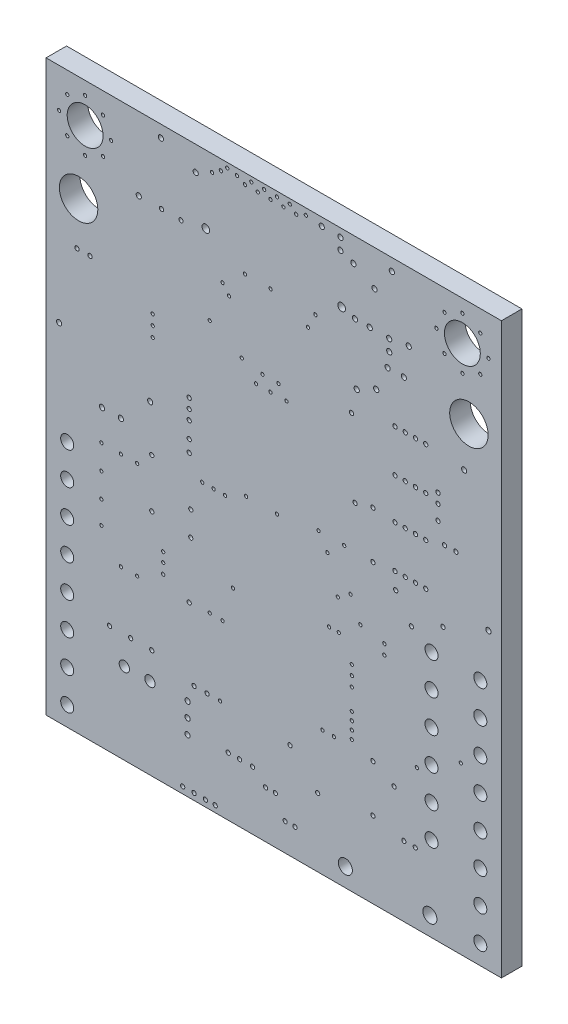
from build123d import *

# Parameters (mm, degrees)
SKETCH1_W           = 35.56
SKETCH1_H           = 44.45
BOARD_OUTLINE_DEPTH = 1.6
SKETCH2_R           = 0.3
SKETCH2_R_2         = 0.127
SKETCH2_R_3         = 0.1651
SKETCH2_R_4         = 0.2032
NPTH_DEPTH          = 2.6
SKETCH3_R           = 1.4
SKETCH3_R_2         = 0.51
SKETCH3_R_3         = 1.5
SKETCH3_R_4         = 0.55
SKETCH3_R_5         = 0.4
PTH_DEPTH           = 2.6


with BuildPart() as part:
    # Sketch1 → Board_Outline (new body)
    with BuildSketch(Plane.XY):
        with Locations((17.78, 22.225)):
            Rectangle(SKETCH1_W, SKETCH1_H)
    extrude(amount=BOARD_OUTLINE_DEPTH)

    # Sketch2 → NPTH (cut, through all)
    with BuildSketch(Plane.XY):
        with Locations((23.08, 39.14)):
            Circle(SKETCH2_R)
        with Locations((12.48, 39.14)):
            Circle(SKETCH2_R)
        with Locations((32.385, 12.954)):
            Circle(SKETCH2_R_2)
        with Locations((15.621, 22.606)):
            Circle(SKETCH2_R_2)
        with Locations((28.848, 23.368)):
            Circle(SKETCH2_R_3)
        with Locations((13.589, 7.747)):
            Circle(SKETCH2_R_2)
        with Locations((19.53, 43.6372)):
            Circle(SKETCH2_R_2)
        with Locations((24.543, 18.383)):
            Circle(SKETCH2_R_2)
        with Locations((16.395, 30.607)):
            Circle(SKETCH2_R_2)
        with Locations((22.098, 17.018)):
            Circle(SKETCH2_R_2)
        with Locations((16.895, 31.496)):
            Circle(SKETCH2_R_2)
        with Locations((22.86, 17.018)):
            Circle(SKETCH2_R_2)
        with Locations((12.78, 33.067)):
            Circle(SKETCH2_R_2)
        with Locations((15.53, 43.6372)):
            Circle(SKETCH2_R_2)
        with Locations((12.192, 21.844)):
            Circle(SKETCH2_R_2)
        with Locations((16.03, 44.069)):
            Circle(SKETCH2_R_2)
        with Locations((13.081, 21.844)):
            Circle(SKETCH2_R_2)
        with Locations((16.53, 43.6372)):
            Circle(SKETCH2_R_2)
        with Locations((13.97, 21.844)):
            Circle(SKETCH2_R_2)
        with Locations((17.03, 44.069)):
            Circle(SKETCH2_R_2)
        with Locations((18.149, 31.496)):
            Circle(SKETCH2_R_2)
        with Locations((18.03, 44.069)):
            Circle(SKETCH2_R_2)
        with Locations((12.78, 13.288)):
            Circle(SKETCH2_R_2)
        with Locations((19.03, 44.069)):
            Circle(SKETCH2_R_2)
        with Locations((13.78, 13.272)):
            Circle(SKETCH2_R_2)
        with Locations((17.526, 30.607)):
            Circle(SKETCH2_R_2)
        with Locations((18.034, 22.606)):
            Circle(SKETCH2_R_2)
        with Locations((18.776, 30.627)):
            Circle(SKETCH2_R_2)
        with Locations((22.781, 19.383)):
            Circle(SKETCH2_R_2)
        with Locations((15.28, 31.79)):
            Circle(SKETCH2_R_2)
        with Locations((18.53, 43.6372)):
            Circle(SKETCH2_R_2)
        with Locations((4.318, 20.574)):
            Circle(SKETCH2_R_2)
        with Locations((4.318, 16.764)):
            Circle(SKETCH2_R_2)
        with Locations((8.255, 21.717)):
            Circle(SKETCH2_R_3)
        with Locations((5.842, 20.574)):
            Circle(SKETCH2_R_2)
        with Locations((7.112, 12.954)):
            Circle(SKETCH2_R_2)
        with Locations((30.988, 21.463)):
            Circle(SKETCH2_R_3)
        with Locations((27.305, 22.098)):
            Circle(SKETCH2_R_3)
        with Locations((4.318, 18.669)):
            Circle(SKETCH2_R_2)
        with Locations((4.318, 14.986)):
            Circle(SKETCH2_R_2)
        with Locations((30.607, 30.353)):
            Circle(SKETCH2_R_3)
        with Locations((28.829, 5.461)):
            Circle(SKETCH2_R_3)
        with Locations((27.94, 5.461)):
            Circle(SKETCH2_R_3)
        with Locations((5.842, 12.954)):
            Circle(SKETCH2_R_2)
        with Locations((11.303, 17.653)):
            Circle(SKETCH2_R_3)
        with Locations((7.112, 20.574)):
            Circle(SKETCH2_R_2)
        with Locations((11.176, 26.289)):
            Circle(SKETCH2_R_3)
        with Locations((11.176, 27.051)):
            Circle(SKETCH2_R_3)
        with Locations((6.604, 8.509)):
            Circle(SKETCH2_R_3)
        with Locations((8.255, 8.509)):
            Circle(SKETCH2_R_3)
        with Locations((19.05, 7.493)):
            Circle(SKETCH2_R_3)
        with Locations((1.016, 27.051)):
            Circle(SKETCH2_R_4)
        with Locations((4.3688, 22.987)):
            Circle(SKETCH2_R_4)
        with Locations((25.527, 26.797)):
            Circle(SKETCH2_R_3)
        with Locations((25.527, 5.969)):
            Circle(SKETCH2_R_3)
        with Locations((30.607, 29.591)):
            Circle(SKETCH2_R_3)
        with Locations((11.176, 13.208)):
            Circle(SKETCH2_R_3)
        with Locations((11.176, 25.527)):
            Circle(SKETCH2_R_3)
        with Locations((15.113, 4.572)):
            Circle(SKETCH2_R_3)
        with Locations((14.224, 4.572)):
            Circle(SKETCH2_R_3)
        with Locations((16.129, 4.572)):
            Circle(SKETCH2_R_3)
        with Locations((11.557, 7.747)):
            Circle(SKETCH2_R_3)
        with Locations((24.13, 26.416)):
            Circle(SKETCH2_R_3)
        with Locations((34.544, 22.987)):
            Circle(SKETCH2_R_4)
        with Locations((28.525, 20.27)):
            Circle(SKETCH2_R_3)
        with Locations((28.848, 26.67)):
            Circle(SKETCH2_R_3)
        with Locations((32.648, 32.902)):
            Circle(SKETCH2_R_4)
        with Locations((23.85, 32.359)):
            Circle(SKETCH2_R_3)
        with Locations((17.907, 3.683)):
            Circle(SKETCH2_R_3)
        with Locations((17.145, 3.683)):
            Circle(SKETCH2_R_3)
        with Locations((11.049, 5.334)):
            Circle(SKETCH2_R_4)
        with Locations((25.781, 34.925)):
            Circle(SKETCH2_R_4)
        with Locations((27.94, 36.83)):
            Circle(SKETCH2_R_4)
        with Locations((26.67, 36.83)):
            Circle(SKETCH2_R_4)
        with Locations((25.654, 41.656)):
            Circle(SKETCH2_R_4)
        with Locations((24.257, 34.163)):
            Circle(SKETCH2_R_4)
        with Locations((17.53, 37.592)):
            Circle(SKETCH2_R_2)
        with Locations((15.53, 37.592)):
            Circle(SKETCH2_R_2)
        with Locations((21.03, 37.592)):
            Circle(SKETCH2_R_2)
        with Locations((11.049, 4.191)):
            Circle(SKETCH2_R_4)
        with Locations((11.049, 6.477)):
            Circle(SKETCH2_R_4)
        with Locations((14.28, 35.489)):
            Circle(SKETCH2_R_2)
        with Locations((14.149, 44.069)):
            Circle(SKETCH2_R_2)
        with Locations((13.78, 36.132)):
            Circle(SKETCH2_R_2)
        with Locations((13.649, 43.6372)):
            Circle(SKETCH2_R_2)
        with Locations((21.59, 9.779)):
            Circle(SKETCH2_R_2)
        with Locations((22.479, 9.779)):
            Circle(SKETCH2_R_2)
        with Locations((9.144, 14.097)):
            Circle(SKETCH2_R_2)
        with Locations((8.325, 29.699)):
            Circle(SKETCH2_R_2)
        with Locations((8.325, 30.499)):
            Circle(SKETCH2_R_2)
        with Locations((9.144, 14.883)):
            Circle(SKETCH2_R_2)
        with Locations((9.144, 15.621)):
            Circle(SKETCH2_R_2)
        with Locations((8.325, 31.299)):
            Circle(SKETCH2_R_2)
        with Locations((3.048, 43.434)):
            Circle(SKETCH2_R_2)
        with Locations((5.08, 41.402)):
            Circle(SKETCH2_R_2)
        with Locations((5.842, 22.987)):
            Circle(SKETCH2_R_4)
        with Locations((7.239, 38.735)):
            Circle(SKETCH2_R_4)
        with Locations((1.016, 41.402)):
            Circle(SKETCH2_R_2)
        with Locations((3.048, 39.37)):
            Circle(SKETCH2_R_2)
        with Locations((8.966, 43.51)):
            Circle(SKETCH2_R_4)
        with Locations((27, 43.51)):
            Circle(SKETCH2_R_4)
        with Locations((24.003, 42.545)):
            Circle(SKETCH2_R_4)
        with Locations((11.684, 42.545)):
            Circle(SKETCH2_R_4)
        with Locations((4.445, 42.799)):
            Circle(SKETCH2_R_2)
        with Locations((1.651, 42.799)):
            Circle(SKETCH2_R_2)
        with Locations((1.651, 40.005)):
            Circle(SKETCH2_R_2)
        with Locations((4.445, 40.005)):
            Circle(SKETCH2_R_2)
        with Locations((32.512, 43.434)):
            Circle(SKETCH2_R_2)
        with Locations((30.48, 41.402)):
            Circle(SKETCH2_R_2)
        with Locations((34.544, 41.402)):
            Circle(SKETCH2_R_2)
        with Locations((32.512, 39.37)):
            Circle(SKETCH2_R_2)
        with Locations((31.115, 42.799)):
            Circle(SKETCH2_R_2)
        with Locations((31.115, 40.005)):
            Circle(SKETCH2_R_2)
        with Locations((33.909, 42.799)):
            Circle(SKETCH2_R_2)
        with Locations((33.909, 40.005)):
            Circle(SKETCH2_R_2)
        with Locations((29.648, 23.368)):
            Circle(SKETCH2_R_3)
        with Locations((14.597, 15.883)):
            Circle(SKETCH2_R_2)
        with Locations((30.607, 28.448)):
            Circle(SKETCH2_R_3)
        with Locations((29.648, 29.845)):
            Circle(SKETCH2_R_3)
        with Locations((26.416, 17.272)):
            Circle(SKETCH2_R_2)
        with Locations((28.848, 29.845)):
            Circle(SKETCH2_R_3)
        with Locations((26.416, 18.034)):
            Circle(SKETCH2_R_2)
        with Locations((28.048, 29.845)):
            Circle(SKETCH2_R_3)
        with Locations((27.248, 26.67)):
            Circle(SKETCH2_R_3)
        with Locations((28.048, 26.67)):
            Circle(SKETCH2_R_3)
        with Locations((27.248, 29.845)):
            Circle(SKETCH2_R_3)
        with Locations((21.28, 23.114)):
            Circle(SKETCH2_R_2)
        with Locations((23.876, 11.557)):
            Circle(SKETCH2_R_2)
        with Locations((23.876, 12.192)):
            Circle(SKETCH2_R_2)
        with Locations((23.876, 10.287)):
            Circle(SKETCH2_R_2)
        with Locations((23.876, 10.922)):
            Circle(SKETCH2_R_2)
        with Locations((21.971, 21.971)):
            Circle(SKETCH2_R_2)
        with Locations((23.28, 23.114)):
            Circle(SKETCH2_R_2)
        with Locations((20.447, 36.449)):
            Circle(SKETCH2_R_2)
        with Locations((23.78, 20.066)):
            Circle(SKETCH2_R_2)
        with Locations((23.876, 13.843)):
            Circle(SKETCH2_R_2)
        with Locations((23.876, 14.605)):
            Circle(SKETCH2_R_2)
        with Locations((28.956, 10.922)):
            Circle(SKETCH2_R_2)
        with Locations((23.876, 15.367)):
            Circle(SKETCH2_R_2)
        with Locations((21.209, 5.334)):
            Circle(SKETCH2_R_3)
        with Locations((27.178, 8.763)):
            Circle(SKETCH2_R_3)
        with Locations((11.303, 19.558)):
            Circle(SKETCH2_R_3)
        with Locations((25.527, 23.114)):
            Circle(SKETCH2_R_3)
        with Locations((11.176, 24.257)):
            Circle(SKETCH2_R_3)
        with Locations((8.255, 17.907)):
            Circle(SKETCH2_R_3)
        with Locations((3.429, 32.766)):
            Circle(SKETCH2_R_3)
        with Locations((11.176, 23.33)):
            Circle(SKETCH2_R_3)
        with Locations((4.953, 8.509)):
            Circle(SKETCH2_R_3)
        with Locations((25.527, 9.652)):
            Circle(SKETCH2_R_3)
        with Locations((2.413, 32.766)):
            Circle(SKETCH2_R_3)
        with Locations((28.321, 39.116)):
            Circle(SKETCH2_R_4)
        with Locations((8.128, 25.273)):
            Circle(SKETCH2_R_4)
        with Locations((12.573, 7.747)):
            Circle(SKETCH2_R_3)
        with Locations((28.048, 23.368)):
            Circle(SKETCH2_R_3)
        with Locations((27.248, 23.368)):
            Circle(SKETCH2_R_3)
        with Locations((29.648, 26.67)):
            Circle(SKETCH2_R_3)
        with Locations((27.248, 33.147)):
            Circle(SKETCH2_R_3)
        with Locations((29.648, 33.147)):
            Circle(SKETCH2_R_3)
        with Locations((28.048, 33.147)):
            Circle(SKETCH2_R_3)
        with Locations((28.848, 33.147)):
            Circle(SKETCH2_R_3)
        with Locations((25.273, 38.862)):
            Circle(SKETCH2_R_4)
        with Locations((24.13, 38.862)):
            Circle(SKETCH2_R_4)
        with Locations((22.987, 43.815)):
            Circle(SKETCH2_R_4)
        with Locations((22.987, 42.926)):
            Circle(SKETCH2_R_4)
        with Locations((31.115, 27.051)):
            Circle(SKETCH2_R_3)
        with Locations((32.004, 27.051)):
            Circle(SKETCH2_R_3)
        with Locations((12.954, 43.18)):
            Circle(SKETCH2_R_2)
        with Locations((14.903, 43.942)):
            Circle(SKETCH2_R_2)
        with Locations((17.53, 43.6372)):
            Circle(SKETCH2_R_2)
        with Locations((20.284, 43.942)):
            Circle(SKETCH2_R_2)
        with Locations((9.017, 38.735)):
            Circle(SKETCH2_R_3)
        with Locations((10.541, 38.735)):
            Circle(SKETCH2_R_3)
        with Locations((13.208, 0.508)):
            Circle(SKETCH2_R_3)
        with Locations((12.446, 0.508)):
            Circle(SKETCH2_R_3)
        with Locations((11.557, 0.508)):
            Circle(SKETCH2_R_3)
        with Locations((10.668, 0.508)):
            Circle(SKETCH2_R_3)
        with Locations((26.797, 37.973)):
            Circle(SKETCH2_R_4)
        with Locations((26.797, 38.862)):
            Circle(SKETCH2_R_4)
        with Locations((21.53, 43.8185)):
            Circle(SKETCH2_R_4)
        with Locations((18.669, 2.159)):
            Circle(SKETCH2_R_3)
        with Locations((19.431, 2.159)):
            Circle(SKETCH2_R_3)
    extrude(amount=NPTH_DEPTH, mode=Mode.SUBTRACT)

    # Sketch3 → PTH (cut, through all)
    with BuildSketch(Plane.XY):
        with Locations((3.05, 41.4)):
            Circle(SKETCH3_R)
        with Locations((32.51, 41.4)):
            Circle(SKETCH3_R)
        with Locations((1.65, 19.3)):
            Circle(SKETCH3_R_2)
        with Locations((1.65, 16.76)):
            Circle(SKETCH3_R_2)
        with Locations((1.65, 14.22)):
            Circle(SKETCH3_R_2)
        with Locations((1.65, 11.68)):
            Circle(SKETCH3_R_2)
        with Locations((1.65, 9.14)):
            Circle(SKETCH3_R_2)
        with Locations((1.65, 6.6)):
            Circle(SKETCH3_R_2)
        with Locations((1.65, 4.06)):
            Circle(SKETCH3_R_2)
        with Locations((1.65, 1.52)):
            Circle(SKETCH3_R_2)
        with Locations((33.91, 19.3)):
            Circle(SKETCH3_R_2)
        with Locations((33.91, 16.76)):
            Circle(SKETCH3_R_2)
        with Locations((33.91, 14.22)):
            Circle(SKETCH3_R_2)
        with Locations((33.91, 11.68)):
            Circle(SKETCH3_R_2)
        with Locations((33.91, 9.14)):
            Circle(SKETCH3_R_2)
        with Locations((33.91, 6.6)):
            Circle(SKETCH3_R_2)
        with Locations((33.91, 4.06)):
            Circle(SKETCH3_R_2)
        with Locations((33.91, 1.52)):
            Circle(SKETCH3_R_2)
        with Locations((30.1, 19.3)):
            Circle(SKETCH3_R_2)
        with Locations((30.1, 16.76)):
            Circle(SKETCH3_R_2)
        with Locations((30.1, 14.22)):
            Circle(SKETCH3_R_2)
        with Locations((30.1, 11.68)):
            Circle(SKETCH3_R_2)
        with Locations((30.1, 9.14)):
            Circle(SKETCH3_R_2)
        with Locations((30.1, 6.6)):
            Circle(SKETCH3_R_2)
        with Locations((2.54, 36.2)):
            Circle(SKETCH3_R_3)
        with Locations((33.02, 36.2)):
            Circle(SKETCH3_R_3)
        with Locations((23.37, 1.45)):
            Circle(SKETCH3_R_4)
        with Locations((29.97, 1.45)):
            Circle(SKETCH3_R_4)
        with Locations((6.11, 6.35)):
            Circle(SKETCH3_R_5)
        with Locations((8.11, 6.35)):
            Circle(SKETCH3_R_5)
    extrude(amount=PTH_DEPTH, mode=Mode.SUBTRACT)


solid = part.part
